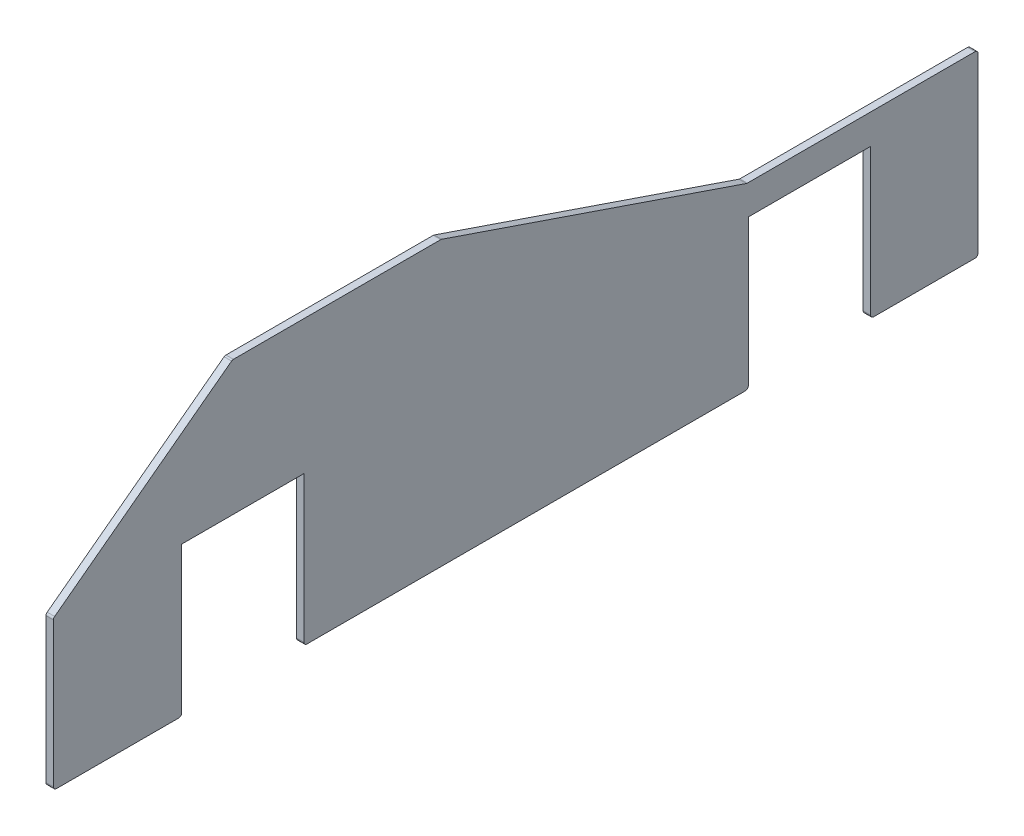
from build123d import *

# Parameters (mm, degrees)
SKETCH1_W           = 620
SKETCH1_H           = 190
BOSS_EXTRUDE1_DEPTH = 5
SKETCH2_W           = 82
SKETCH2_H           = 100
CUT_EXTRUDE1_DEPTH  = 5
FILLET1_R           = 2


with BuildPart() as part:
    # Sketch1 → Boss-Extrude1 (new body)
    with BuildSketch(Plane(origin=(0, 0, 0), x_dir=(0, 0, -1), z_dir=(1, 0, 0))):
        Rectangle(SKETCH1_W, SKETCH1_H)
    extrude(amount=BOSS_EXTRUDE1_DEPTH)

    # Sketch2 → Cut-Extrude1 (cut)
    with BuildSketch(Plane(origin=(5, 0, 0), x_dir=(0, 0, -1), z_dir=(1, 0, 0))):
        Polygon((-310, 95), (-310, 5), (-190, 95), align=None)
        Polygon((310, 95), (-50, 95), (155, 25), (310, 25), align=None)
        with Locations((-183, -45)):
            Rectangle(SKETCH2_W, SKETCH2_H)
        with Locations((197, -45)):
            Rectangle(SKETCH2_W, SKETCH2_H)
    extrude(amount=-CUT_EXTRUDE1_DEPTH, mode=Mode.SUBTRACT)

    # Fillet1
    fillet1_edges = [part.edges().sort_by_distance(p)[0] for p in [
        (2.5, 25, -155),
        (2.5, 95, 50),
        (2.5, 25, -310),
        (2.5, -95, 142),
        (2.5, -95, 224),
        (2.5, -95, -238),
        (2.5, -95, -156),
        (2.5, 5, 310),
        (2.5, 95, 190),
        (2.5, -95, -310),
        (2.5, -95, 310),
    ]]
    fillet(fillet1_edges, radius=FILLET1_R)


solid = part.part
